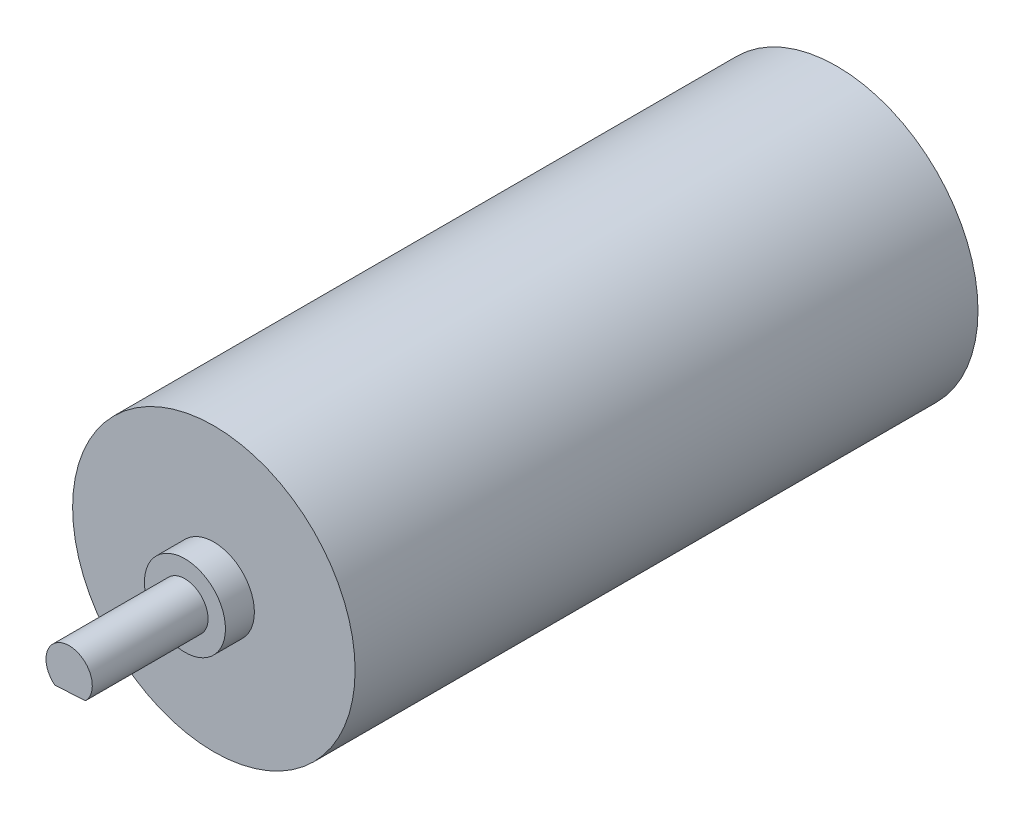
from build123d import *

# Parameters (mm, degrees)
ESQUISSE1_R             = 12.2
BOSS_EXTRU_1_DEPTH      = 26.9
ESQUISSE2_R             = 3.5
BOSS_EXTRU_2_DEPTH      = 2.5
ESQUISSE3_R             = 2
BOSS_EXTRU_3_DEPTH      = 10
ENL_V_MAT_EXTRU_1_DEPTH = 8


with BuildPart() as part:
    # Esquisse1 → Boss.-Extru.1 (new body, symmetric)
    with BuildSketch(Plane.XY):
        Circle(ESQUISSE1_R)
    extrude(amount=BOSS_EXTRU_1_DEPTH, both=True)

    # Esquisse2 → Boss.-Extru.2 (add)
    with BuildSketch(Plane.XY.offset(26.9)):
        Circle(ESQUISSE2_R)
    extrude(amount=BOSS_EXTRU_2_DEPTH)

    # Esquisse3 → Boss.-Extru.3 (add)
    with BuildSketch(Plane.XY.offset(29.4)):
        Circle(ESQUISSE3_R)
    extrude(amount=BOSS_EXTRU_3_DEPTH)

    # Esquisse4 → Enlèv. mat.-Extru.1 (cut)
    with BuildSketch(Plane.XY.offset(39.4)):
        with BuildLine():
            Line((-1.233818862, -1.574068301), (1.407495119, -1.42090024))
            ThreePointArc((1.407495119, -1.42090024), (0.115784171, -1.996645694), (-1.233818862, -1.574068301))
        make_face()
    extrude(amount=-ENL_V_MAT_EXTRU_1_DEPTH, mode=Mode.SUBTRACT)


solid = part.part
